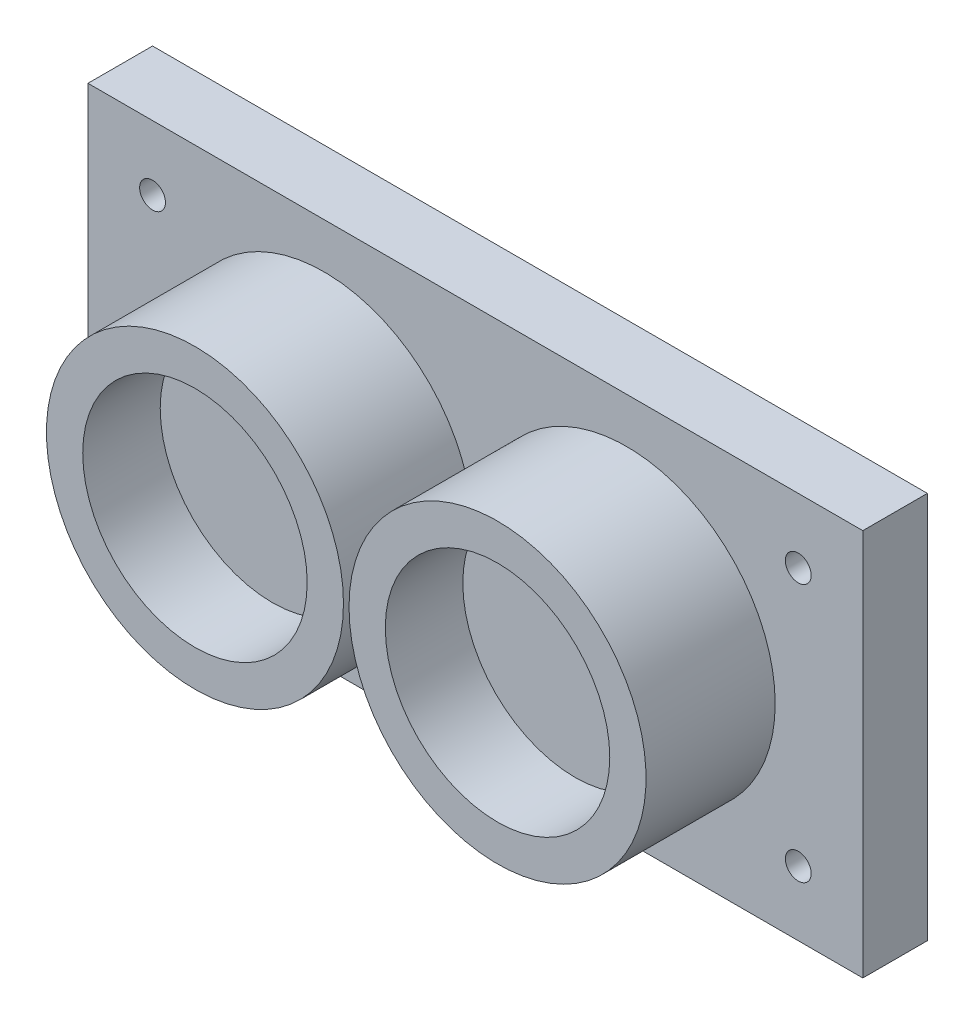
from build123d import *

# Parameters (mm, degrees)
SKETCH1_W           = 60
SKETCH1_H           = 30
BOSS_EXTRUDE2_DEPTH = 5
SKETCH2_R           = 11.5
BOSS_EXTRUDE3_DEPTH = 10
SKETCH3_R           = 8.69
CUT_EXTRUDE2_DEPTH  = 6
SKETCH4_R           = 1
CUT_EXTRUDE4_DEPTH  = 10


with BuildPart() as part:
    # Sketch1 → Boss-Extrude2 (new body)
    with BuildSketch(Plane.XY):
        Rectangle(SKETCH1_W, SKETCH1_H)
    extrude(amount=BOSS_EXTRUDE2_DEPTH)

    # Sketch2 → Boss-Extrude3 (add)
    with BuildSketch(Plane.XY.offset(5)):
        with Locations((-11.715, 0)):
            Circle(SKETCH2_R)
        with Locations((11.715, 0)):
            Circle(SKETCH2_R)
    extrude(amount=BOSS_EXTRUDE3_DEPTH)

    # Sketch3 → Cut-Extrude2 (cut)
    with BuildSketch(Plane.XY.offset(15)):
        with Locations((-11.715, 0)):
            Circle(SKETCH3_R)
        with Locations((11.715, 0)):
            Circle(SKETCH3_R)
    extrude(amount=-CUT_EXTRUDE2_DEPTH, mode=Mode.SUBTRACT)

    # Sketch4 → Cut-Extrude4 (cut)
    with BuildSketch(Plane.XY.offset(5)):
        with Locations((-25, 10)):
            Circle(SKETCH4_R)
        with Locations((25, 10)):
            Circle(SKETCH4_R)
        with Locations((25, -10)):
            Circle(SKETCH4_R)
        with Locations((-25, -10)):
            Circle(SKETCH4_R)
    extrude(amount=-CUT_EXTRUDE4_DEPTH, mode=Mode.SUBTRACT)


solid = part.part
